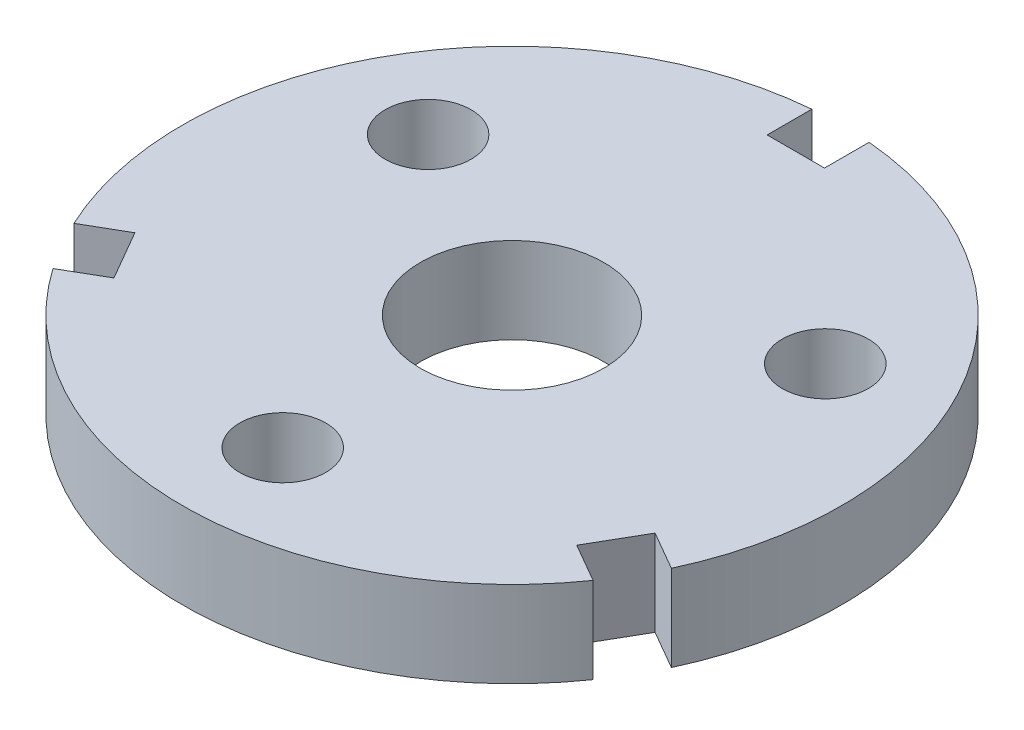
from build123d import *

# Parameters (mm, degrees)
SKETCH1_R           = 16
SKETCH1_R_2         = 7.5
BOSS_EXTRUDE1_DEPTH = 7.5


with BuildPart() as part:
    # Sketch1 → Boss-Extrude1 (new body, symmetric)
    with BuildSketch(Plane(origin=(0, 0, 0), x_dir=(1, 0, 0), z_dir=(0, 1, 0))):
        with BuildLine():
            Line((52.107837082, -24.310971075), (45.368257487, -20.419872981))
            Line((45.368257487, -20.419872981), (40.368257487, -29.080127019))
            Line((40.368257487, -29.080127019), (47.107837082, -32.971225112))
            ThreePointArc((47.107837082, -32.971225112), (0, -57.5), (-47.107837082, -32.971225112))
            Line((-47.107837082, -32.971225112), (-40.368257487, -29.080127019))
            Line((-40.368257487, -29.080127019), (-45.368257487, -20.419872981))
            Line((-45.368257487, -20.419872981), (-52.107837082, -24.310971075))
            ThreePointArc((-52.107837082, -24.310971075), (-49.796460718, 28.75), (-5, 57.282196187))
            Line((-5, 57.282196187), (-5, 49.5))
            Line((-5, 49.5), (5, 49.5))
            Line((5, 49.5), (5, 57.282196187))
            ThreePointArc((5, 57.282196187), (49.796460718, 28.75), (52.107837082, -24.310971075))
        make_face()
        Circle(SKETCH1_R, mode=Mode.SUBTRACT)
        with Locations((0, -40)):
            Circle(SKETCH1_R_2, mode=Mode.SUBTRACT)
        with Locations((-34.641016151, 20)):
            Circle(SKETCH1_R_2, mode=Mode.SUBTRACT)
        with Locations((34.641016151, 20)):
            Circle(SKETCH1_R_2, mode=Mode.SUBTRACT)
    extrude(amount=BOSS_EXTRUDE1_DEPTH, both=True)


solid = part.part
